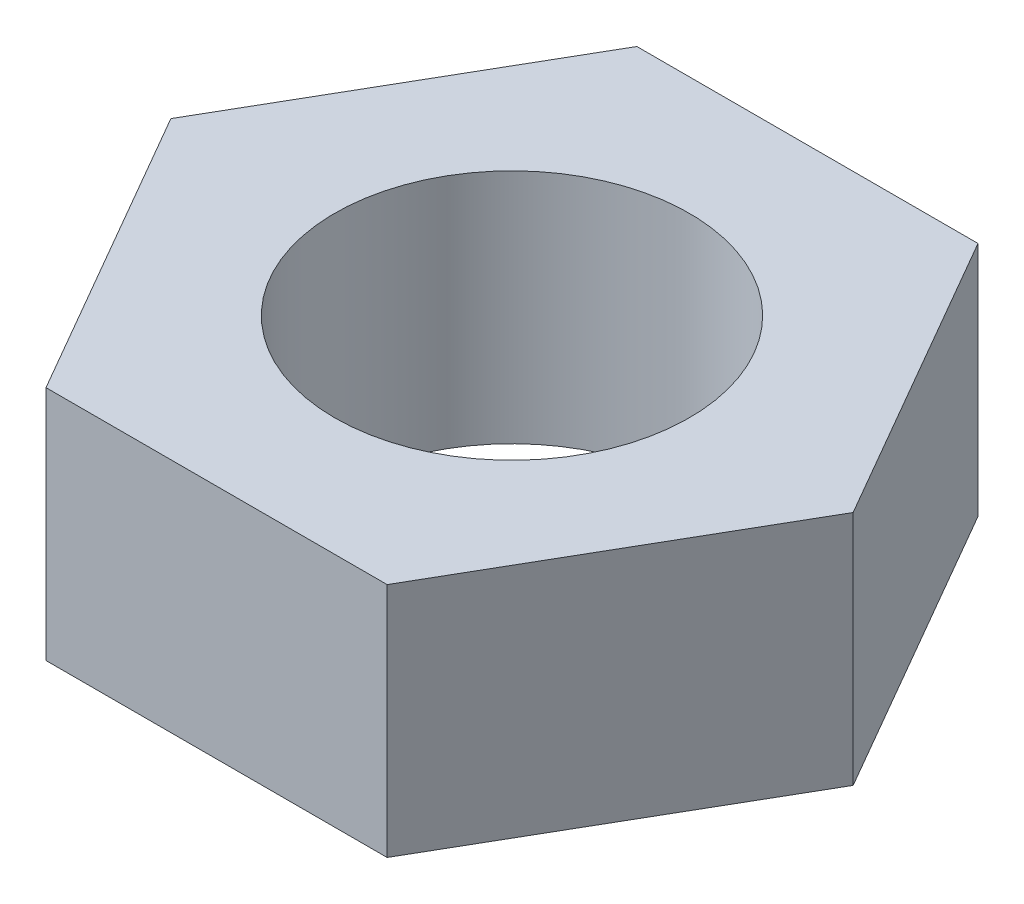
from build123d import *

# Parameters (mm, degrees)
SKETCH1_R           = 2.25
BOSS_EXTRUDE1_DEPTH = 3


with BuildPart() as part:
    # Sketch1 → Boss-Extrude1 (new body)
    with BuildSketch(Plane(origin=(0, 0, 0), x_dir=(1, 0, 0), z_dir=(0, 1, 0))):
        Polygon((2.165063509, 3.75), (-2.165063509, 3.75), (-4.330127019, 0), (-2.165063509, -3.75), (2.165063509, -3.75), (4.330127019, 0), align=None)
        Circle(SKETCH1_R, mode=Mode.SUBTRACT)
    extrude(amount=BOSS_EXTRUDE1_DEPTH)


solid = part.part
